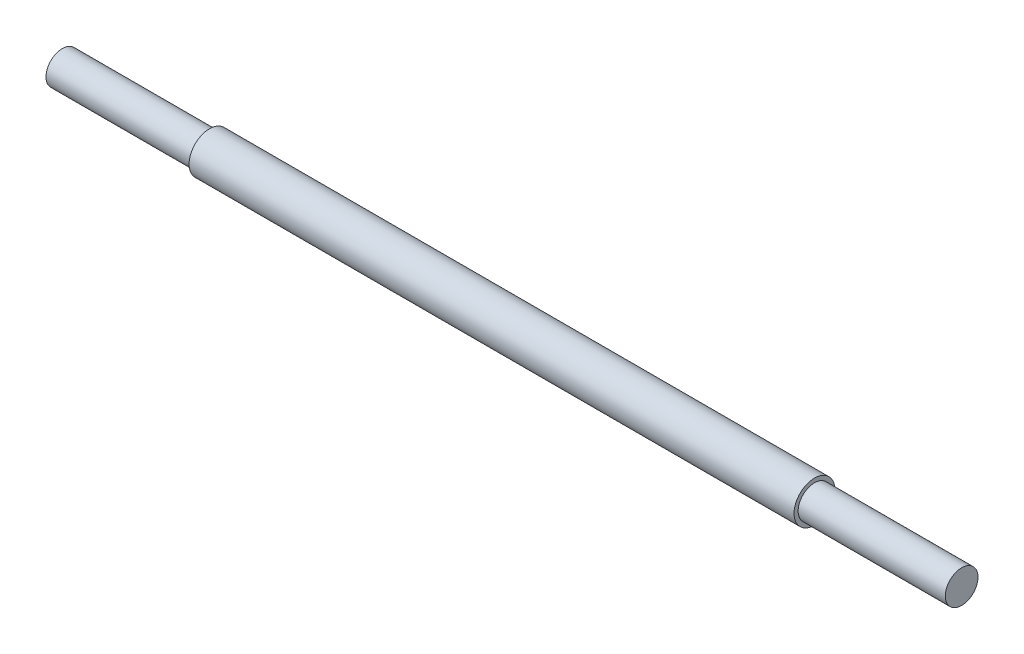
from build123d import *

# Parameters (mm, degrees)
SKETCH1_R           = 2.5
BOSS_EXTRUDE1_DEPTH = 45
SKETCH2_R           = 2.5
SKETCH2_R_2         = 2
CUT_EXTRUDE1_DEPTH  = 8
SKETCH3_R           = 2.5
SKETCH3_R_2         = 2
CUT_EXTRUDE2_DEPTH  = 8
SKETCH4_R           = 2
BOSS_EXTRUDE2_DEPTH = 10
SKETCH5_R           = 2
BOSS_EXTRUDE3_DEPTH = 10


with BuildPart() as part:
    # Sketch1 → Boss-Extrude1 (new body, symmetric)
    with BuildSketch(Plane(origin=(0, 0, 0), x_dir=(0, 0, -1), z_dir=(1, 0, 0))):
        Circle(SKETCH1_R)
    extrude(amount=BOSS_EXTRUDE1_DEPTH, both=True)

    # Sketch2 → Cut-Extrude1 (cut)
    with BuildSketch(Plane(origin=(45, 0, 0), x_dir=(0, 0, -1), z_dir=(1, 0, 0))):
        Circle(SKETCH2_R)
        Circle(SKETCH2_R_2, mode=Mode.SUBTRACT)
    extrude(amount=-CUT_EXTRUDE1_DEPTH, mode=Mode.SUBTRACT)

    # Sketch3 → Cut-Extrude2 (cut)
    with BuildSketch(Plane.ZY.offset(45)):
        Circle(SKETCH3_R)
        Circle(SKETCH3_R_2, mode=Mode.SUBTRACT)
    extrude(amount=-CUT_EXTRUDE2_DEPTH, mode=Mode.SUBTRACT)

    # Sketch4 → Boss-Extrude2 (add)
    with BuildSketch(Plane(origin=(45, 0, 0), x_dir=(0, 0, -1), z_dir=(1, 0, 0))):
        Circle(SKETCH4_R)
    extrude(amount=BOSS_EXTRUDE2_DEPTH)

    # Sketch5 → Boss-Extrude3 (add)
    with BuildSketch(Plane.ZY.offset(45)):
        Circle(SKETCH5_R)
    extrude(amount=BOSS_EXTRUDE3_DEPTH)


solid = part.part
